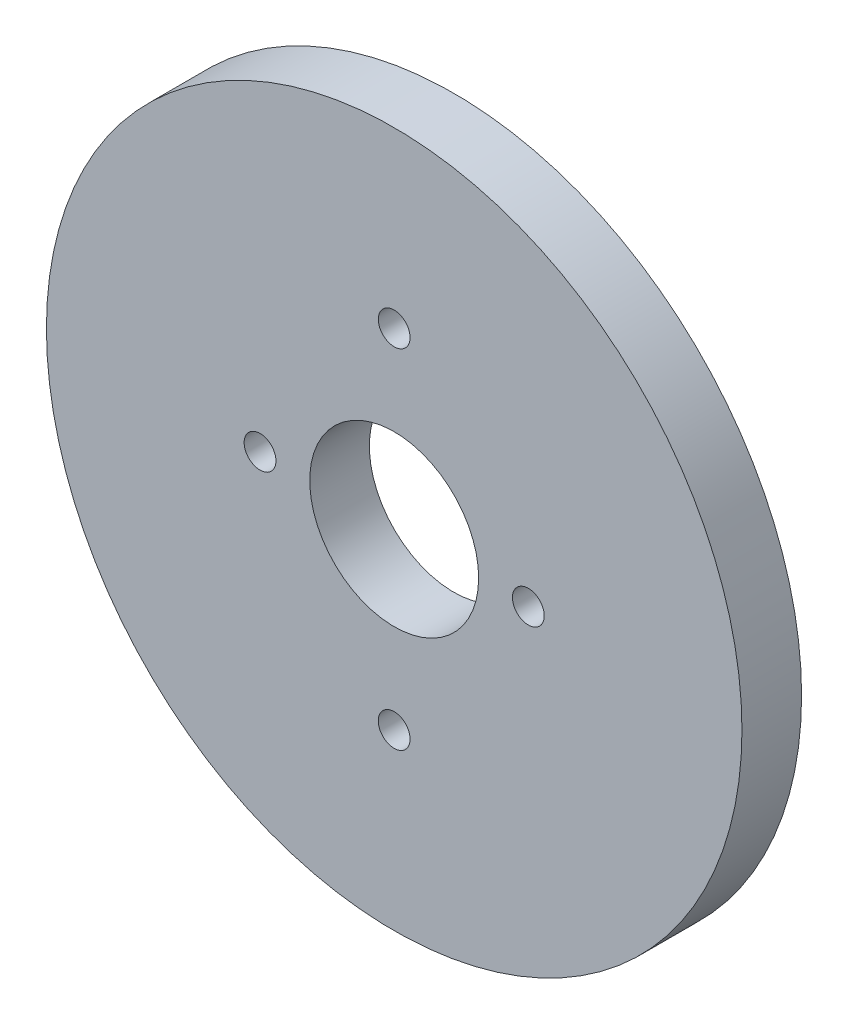
from build123d import *

# Parameters (mm, degrees)
SKETCH1_R           = 17.5
SKETCH1_R_2         = 4.25
SKETCH1_R_3         = 0.8
BOSS_EXTRUDE1_DEPTH = 3


with BuildPart() as part:
    # Sketch1 → Boss-Extrude1 (new body)
    with BuildSketch(Plane.XY):
        Circle(SKETCH1_R)
        Circle(SKETCH1_R_2, mode=Mode.SUBTRACT)
        with Locations((6.75, 0)):
            Circle(SKETCH1_R_3, mode=Mode.SUBTRACT)
        with Locations((0, 8.75)):
            Circle(SKETCH1_R_3, mode=Mode.SUBTRACT)
        with Locations((0, -8.75)):
            Circle(SKETCH1_R_3, mode=Mode.SUBTRACT)
        with Locations((-6.75, 0)):
            Circle(SKETCH1_R_3, mode=Mode.SUBTRACT)
    extrude(amount=BOSS_EXTRUDE1_DEPTH)


solid = part.part
